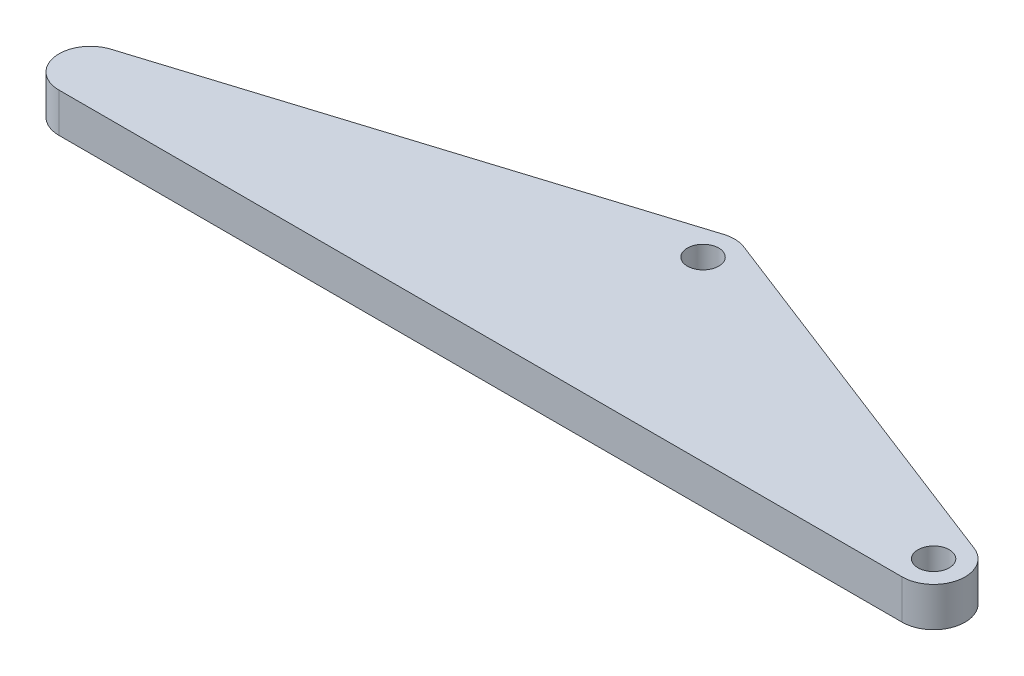
from build123d import *

# Parameters (mm, degrees)
SKETCH_1_R      = 2
EXTRUDE_1_DEPTH = 5


with BuildPart() as part:
    # 草图1 → 凸台-拉伸1 (new body)
    with BuildSketch(Plane(origin=(0, 0, 0), x_dir=(1, 0, 0), z_dir=(0, 1, 0))):
        with BuildLine():
            ThreePointArc((-53.6685, 4), (-54.272481718, 3.954137843), (-54.862613484, 3.817603042))
            ThreePointArc((-54.862613484, 3.817603042), (-57.622637843, -0.603981718), (-53.6685, -4))
            ThreePointArc((-53.6685, -4), (-53.064518282, -3.954137843), (-52.474386516, -3.817603042))
            Line((-52.474386516, -3.817603042), (-27.481364025, 4))
            Line((-27.481364025, 4), (-53.6685, 4))
        make_face()
        with Locations((-53.6685, 0)):
            Circle(SKETCH_1_R, mode=Mode.SUBTRACT)
        with BuildLine():
            Line((4.544386516, 22.399603042), (-54.862613484, 3.817603042))
            ThreePointArc((-54.862613484, 3.817603042), (-54.272481718, 3.954137843), (-53.6685, 4))
            Line((-53.6685, 4), (-27.481364025, 4))
            Line((-27.481364025, 4), (5.597201207, 14.346691453))
            Line((5.597201207, 14.346691453), (4.292598412, 14.852473408))
            ThreePointArc((4.292598412, 14.852473408), (1.740724203, 18.715374202), (4.544386516, 22.399603042))
        make_face()
        with BuildLine():
            ThreePointArc((7.184401588, 22.311526592), (5.871874202, 22.579775797), (4.544386516, 22.399603042))
            ThreePointArc((4.544386516, 22.399603042), (1.740724203, 18.715374202), (4.292598412, 14.852473408))
            Line((4.292598412, 14.852473408), (5.597201207, 14.346691453))
            Line((5.597201207, 14.346691453), (6.932613484, 14.764396958))
            ThreePointArc((6.932613484, 14.764396958), (9.736275797, 18.448625798), (7.184401588, 22.311526592))
        make_face()
        with Locations((5.7385, 18.582)):
            Circle(SKETCH_1_R, mode=Mode.SUBTRACT)
        with BuildLine():
            Line((55.114401588, 3.729526592), (7.184401588, 22.311526592))
            ThreePointArc((7.184401588, 22.311526592), (9.736275797, 18.448625798), (6.932613484, 14.764396958))
            Line((6.932613484, 14.764396958), (5.597201207, 14.346691453))
            Line((5.597201207, 14.346691453), (32.285228401, 4))
            Line((32.285228401, 4), (53.6685, 4))
            ThreePointArc((53.6685, 4), (54.403990868, 3.931800247), (55.114401588, 3.729526592))
        make_face()
        with BuildLine():
            ThreePointArc((-52.474386516, -3.817603042), (-53.064518282, -3.954137843), (-53.6685, -4))
            Line((-53.6685, -4), (53.6685, -4))
            ThreePointArc((53.6685, -4), (52.933009132, -3.931800247), (52.222598412, -3.729526592))
            Line((52.222598412, -3.729526592), (32.285228401, 4))
            Line((32.285228401, 4), (-27.481364025, 4))
            Line((-27.481364025, 4), (-52.474386516, -3.817603042))
        make_face()
        with BuildLine():
            ThreePointArc((52.222598412, -3.729526592), (52.933009132, -3.931800247), (53.6685, -4))
            ThreePointArc((53.6685, -4), (57.600300247, -0.735490868), (55.114401588, 3.729526592))
            ThreePointArc((55.114401588, 3.729526592), (54.403990868, 3.931800247), (53.6685, 4))
            Line((53.6685, 4), (32.285228401, 4))
            Line((32.285228401, 4), (52.222598412, -3.729526592))
        make_face()
        with Locations((53.6685, 0)):
            Circle(SKETCH_1_R, mode=Mode.SUBTRACT)
        Polygon((5.597201207, 14.346691453), (-27.481364025, 4), (32.285228401, 4), align=None)
        with Locations((-53.6685, 0)):
            Circle(SKETCH_1_R)
    extrude(amount=EXTRUDE_1_DEPTH)


solid = part.part
